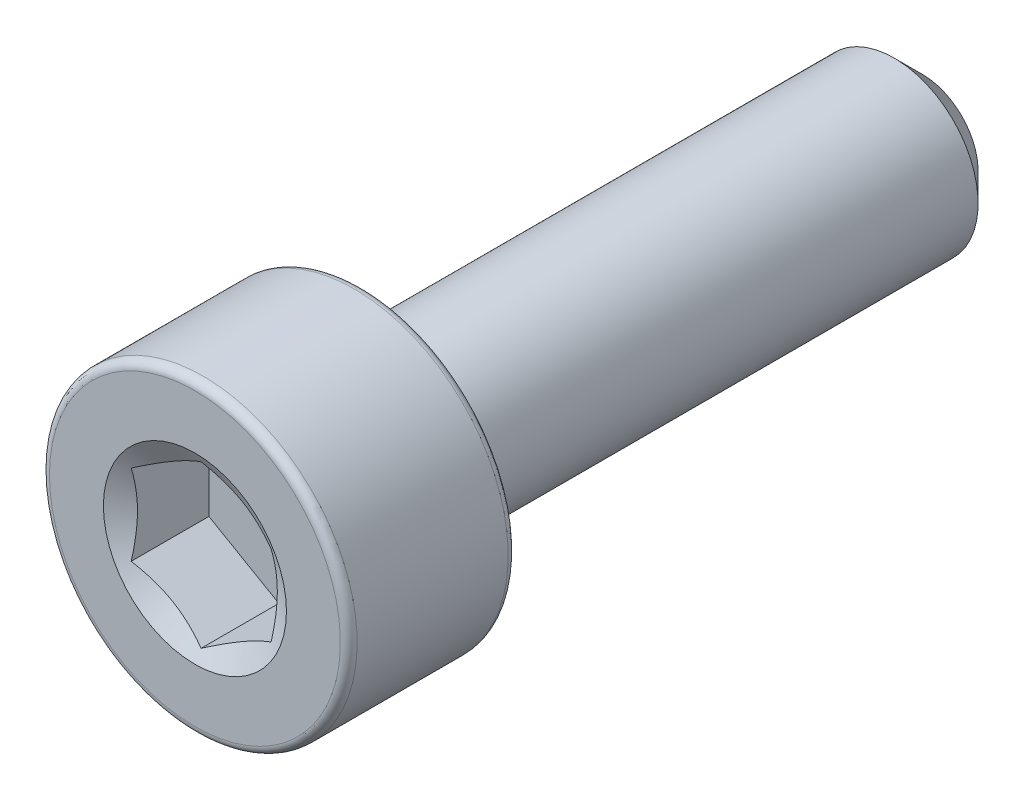
from build123d import *

# Parameters (mm, degrees)
CUT_EXTRUDE1_START = 6.5
CUT_EXTRUDE1_DEPTH = 1.5


with BuildPart() as part:
    # Sketch2 → Revolve1 (revolve)
    with BuildSketch(Plane(origin=(0, 0, 0), x_dir=(0, 0, -1), z_dir=(1, 0, 0)), mode=Mode.PRIVATE) as revolve1_sk:
        with BuildLine():
            Line((6.5, 0), (6.5, 1))
            Line((6.5, 1), (6, 1.5))
            Line((6, 1.5), (-3.5, 1.5))
            Line((-3.5, 1.5), (-3.5, 2.6))
            ThreePointArc((-3.5, 2.6), (-3.543933983, 2.706066017), (-3.65, 2.75))
            Line((-3.65, 2.75), (-6.35, 2.75))
            ThreePointArc((-6.35, 2.75), (-6.456066017, 2.706066017), (-6.5, 2.6))
            Line((-6.5, 2.6), (-6.5, 0))
            Line((-6.5, 0), (6.5, 0))
        make_face()
    revolve(revolve1_sk.sketch.rotate(Axis((0, 0, -6.5), (0, 0, 1)), 90), axis=Axis((0, 0, -6.5), (0, 0, 1)))

    # Sketch3 → Cut-Extrude1 (cut)
    with BuildSketch(Plane.XY.offset(CUT_EXTRUDE1_START)):
        Polygon((-1.25, 0.721687836), (-1.25, -0.721687836), (0, -1.443375673), (1.25, -0.721687836), (1.25, 0.721687836), (0, 1.443375673), align=None)
    extrude(amount=-CUT_EXTRUDE1_DEPTH, mode=Mode.SUBTRACT)

    # Cut-Extrude2 cone 1 section (through the dimple's axis) → Cut-Extrude2 (revolve, cut)
    with BuildSketch(Plane(origin=(0, 0, 6.5), x_dir=(0, -1, 0), z_dir=(1, 0, 0))):
        Polygon((0, 0), (1.636146394, 0), (0, 0.944629561), align=None)
    revolve(axis=Axis((0, 0, 6.5), (0, 0, -1)), mode=Mode.SUBTRACT)


solid = part.part
